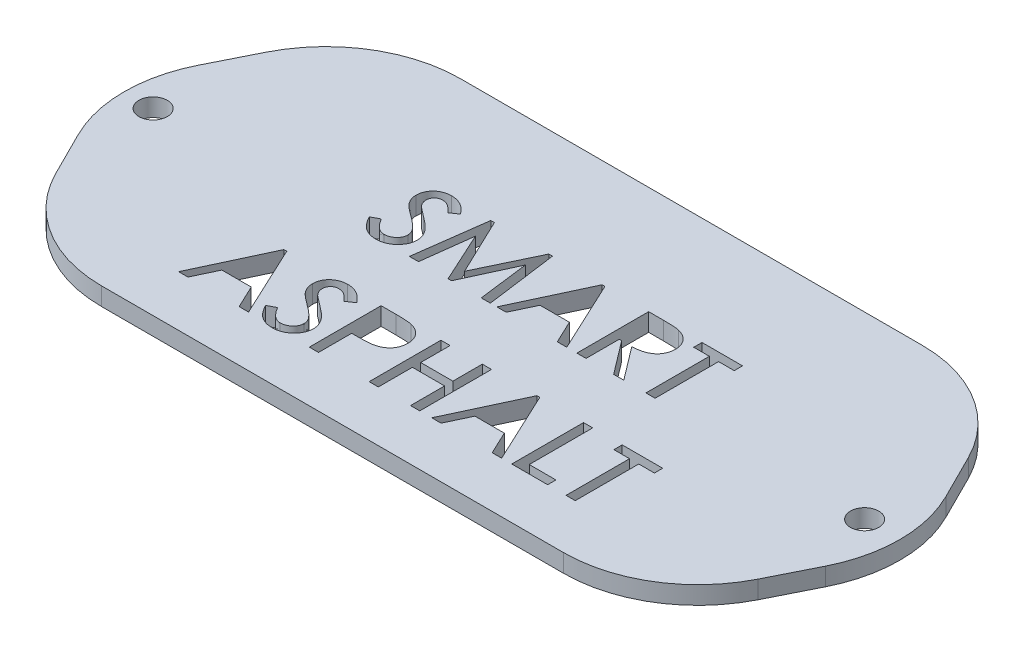
from build123d import *

# Parameters (mm, degrees)
SKETCH1_R           = 1.58
BOSS_EXTRUDE1_DEPTH = 2


with BuildPart() as part:
    # Sketch1 → Boss-Extrude1 (new body)
    with BuildSketch(Plane(origin=(0, 0, 0), x_dir=(1, 0, 0), z_dir=(0, 1, 0))):
        with BuildLine():
            Line((-22.537734094, 16.328045587), (28.921246244, 16.328045587))
            ThreePointArc((28.921246244, 16.328045587), (36.807212925, 14.087807712), (42.337654109, 8.03624952))
            Line((42.337654109, 8.03624952), (44.837654109, 3.03624952))
            ThreePointArc((44.837654109, 3.03624952), (46.421246244, -3.671954413), (44.837654109, -10.380158345))
            Line((44.837654109, -10.380158345), (42.337654109, -15.380158345))
            ThreePointArc((42.337654109, -15.380158345), (36.807212925, -21.431716538), (28.921246244, -23.671954413))
            Line((28.921246244, -23.671954413), (-22.537734094, -23.671954413))
            ThreePointArc((-22.537734094, -23.671954413), (-30.423700776, -21.431716538), (-35.954141959, -15.380158345))
            Line((-35.954141959, -15.380158345), (-38.454141959, -10.380158345))
            ThreePointArc((-38.454141959, -10.380158345), (-40.037734094, -3.671954413), (-38.454141959, 3.03624952))
            Line((-38.454141959, 3.03624952), (-35.954141959, 8.03624952))
            ThreePointArc((-35.954141959, 8.03624952), (-30.423700776, 14.087807712), (-22.537734094, 16.328045587))
        make_face()
        with Locations((-36.808243925, -3.671954413)):
            Circle(SKETCH1_R, mode=Mode.SUBTRACT)
        with Locations((42.491756075, -3.671954413)):
            Circle(SKETCH1_R, mode=Mode.SUBTRACT)
        with BuildLine():
            Line((-14.295423412, -2.085415951), (-13.423628541, -1.620672362))
            add(Edge.make_bspline(
                [(-13.423628541, -1.620672362), (-13.305977541, -1.823822274), (-13.11965558, -2.104826787), (-12.840981878, -2.429013334), (-12.641975401, -2.620035509), (-12.439309358, -2.767503703), (-12.174124296, -2.907234523), (-11.959744017, -2.954550086), (-11.819461874, -2.954005695)],
                knots=[0, 0, 0, 0, 0.32370907, 0.463075941, 0.588607122, 0.703049784, 0.807443722, 1, 1, 1, 1], degree=3))
            add(Edge.make_bspline(
                [(-11.819461874, -2.954005695), (-11.692092155, -2.95470975), (-11.502519693, -2.931184165), (-11.259792303, -2.85822019), (-11.087772674, -2.78133138), (-10.928852745, -2.686985532), (-10.788558793, -2.574802613), (-10.66953084, -2.447786333), (-10.57139736, -2.307668193), (-10.494571355, -2.158069642), (-10.41876587, -1.95177248), (-10.398814457, -1.78786225), (-10.397987515, -1.679967233)],
                knots=[0, 0, 0, 0, 0.179725759, 0.268080593, 0.357295441, 0.44532722, 0.528557861, 0.610268431, 0.690476304, 0.769478029, 0.847320812, 1, 1, 1, 1], degree=3))
            add(Edge.make_bspline(
                [(-10.397987515, -1.679967233), (-10.398026758, -1.554155823), (-10.444622826, -1.28975984), (-10.578321181, -1.057296377), (-10.6576029, -0.94439031)],
                knots=[0, 0, 0, 0, 0.475821556, 1, 1, 1, 1], degree=3))
            add(Edge.make_bspline(
                [(-10.6576029, -0.94439031), (-10.72881015, -0.851847822), (-10.847307389, -0.710190697), (-11.029700348, -0.526800598), (-11.193389654, -0.377355576), (-11.374829744, -0.219291995), (-11.654691855, 0.005896703), (-11.878604026, 0.172823824), (-12.034205464, 0.28637892)],
                knots=[0, 0, 0, 0, 0.189087639, 0.298560917, 0.418529035, 0.547896606, 0.688105638, 1, 1, 1, 1], degree=3))
            add(Edge.make_bspline(
                [(-12.034205464, 0.28637892), (-12.191879719, 0.399998124), (-12.414906191, 0.56550221), (-12.693382792, 0.782241412), (-12.867572439, 0.923745166), (-13.017234179, 1.053653978), (-13.171577156, 1.198226404), (-13.273773111, 1.302249279), (-13.327474694, 1.372917382)],
                knots=[0, 0, 0, 0, 0.344370415, 0.492060575, 0.625259646, 0.741997385, 0.843119601, 1, 1, 1, 1], degree=3))
            add(Edge.make_bspline(
                [(-13.327474694, 1.372917382), (-13.402102599, 1.46411598), (-13.500199247, 1.609591229), (-13.606124497, 1.814459744), (-13.670904852, 1.969206071), (-13.720955313, 2.12686807), (-13.76752052, 2.342319835), (-13.784730726, 2.507291479), (-13.7826029, 2.61810969)],
                knots=[0, 0, 0, 0, 0.261315157, 0.388035482, 0.511326802, 0.633179155, 0.754563498, 1, 1, 1, 1], degree=3))
            add(Edge.make_bspline(
                [(-13.7826029, 2.61810969), (-13.783205657, 2.789736668), (-13.75180998, 3.045415532), (-13.639654848, 3.366516604), (-13.526488342, 3.592433524), (-13.381777054, 3.801080634), (-13.209699504, 3.988334498), (-13.009268975, 4.150188935), (-12.785846887, 4.286604505), (-12.54502764, 4.397101902), (-12.204802693, 4.503406179), (-11.937354408, 4.532406833), (-11.758564438, 4.533173792)],
                knots=[0, 0, 0, 0, 0.165741364, 0.245990119, 0.327410354, 0.408957903, 0.490350364, 0.572108035, 0.656848456, 0.742472606, 0.827297737, 1, 1, 1, 1], degree=3))
            add(Edge.make_bspline(
                [(-11.758564438, 4.533173792), (-11.555658117, 4.530215554), (-11.250841757, 4.503701651), (-10.865660915, 4.383936181), (-10.634691398, 4.285936865), (-10.455261249, 4.185647236), (-10.319555213, 4.095081465), (-10.180466064, 3.992580807), (-10.042384872, 3.873052584), (-9.899990642, 3.742227388), (-9.708670566, 3.538082005), (-9.565317447, 3.377328115), (-9.474910592, 3.260737895)],
                knots=[0, 0, 0, 0, 0.224554627, 0.334220458, 0.444071551, 0.500820262, 0.560831712, 0.624033752, 0.691370994, 0.762285901, 0.837344076, 1, 1, 1, 1], degree=3))
            Line((-9.474910592, 3.260737895), (-10.311449053, 2.687019946))
            add(Edge.make_bspline(
                [(-10.311449053, 2.687019946), (-10.395268369, 2.776742918), (-10.516807362, 2.90574481), (-10.679347695, 3.064428123), (-10.78987395, 3.164936953), (-10.891628852, 3.253677156), (-10.987468947, 3.327659482), (-11.074397321, 3.391241874), (-11.183067067, 3.454266914), (-11.316278178, 3.516636931), (-11.536156228, 3.592164012), (-11.711537375, 3.607533697), (-11.827474694, 3.610096869)],
                knots=[0, 0, 0, 0, 0.200827508, 0.289794372, 0.371423664, 0.44514775, 0.510508429, 0.569413627, 0.62110701, 0.715687751, 0.809620671, 1, 1, 1, 1], degree=3))
            add(Edge.make_bspline(
                [(-11.827474694, 3.610096869), (-11.949476389, 3.610568548), (-12.131009374, 3.58030079), (-12.349199616, 3.475340574), (-12.491525157, 3.366296022), (-12.609707565, 3.231164291), (-12.728901524, 3.014496864), (-12.755686229, 2.825543476), (-12.756961874, 2.699840459)],
                knots=[0, 0, 0, 0, 0.251154334, 0.372198033, 0.495421983, 0.617857606, 0.739464963, 1, 1, 1, 1], degree=3))
            add(Edge.make_bspline(
                [(-12.756961874, 2.699840459), (-12.756045877, 2.614585853), (-12.746080283, 2.48617305), (-12.699074124, 2.322616278), (-12.654719469, 2.20197035), (-12.592546121, 2.083725284), (-12.483289733, 1.923104853), (-12.383439385, 1.810429321), (-12.309846489, 1.738301997)],
                knots=[0, 0, 0, 0, 0.234924047, 0.350690114, 0.466855841, 0.587687679, 0.71677411, 1, 1, 1, 1], degree=3))
            add(Edge.make_bspline(
                [(-12.309846489, 1.738301997), (-12.267367662, 1.695932769), (-12.187611069, 1.632748393), (-12.069646305, 1.537763894), (-11.953377618, 1.444241182), (-11.814394342, 1.341205132), (-11.593190792, 1.172290731), (-11.413905236, 1.04345051), (-11.289013156, 0.951443023)],
                knots=[0, 0, 0, 0, 0.139313951, 0.236560615, 0.352441789, 0.486424821, 0.63905089, 1, 1, 1, 1], degree=3))
            add(Edge.make_bspline(
                [(-11.289013156, 0.951443023), (-11.115577012, 0.825647118), (-10.864991132, 0.640860314), (-10.558318112, 0.382815208), (-10.354949126, 0.206424152), (-10.177000453, 0.03289888), (-10.021128504, -0.134181543), (-9.885389703, -0.293188842), (-9.740380011, -0.495918868), (-9.595638801, -0.745848277), (-9.425357596, -1.140313609), (-9.37416008, -1.452781883), (-9.372346489, -1.655928772)],
                knots=[0, 0, 0, 0, 0.191283692, 0.277593646, 0.357646669, 0.431478927, 0.499277499, 0.561538325, 0.61789992, 0.721500519, 0.818718062, 1, 1, 1, 1], degree=3))
            add(Edge.make_bspline(
                [(-9.372346489, -1.655928772), (-9.373277882, -1.797275354), (-9.393096316, -2.008792566), (-9.466360521, -2.280929737), (-9.54461972, -2.477473272), (-9.642345475, -2.669142814), (-9.763487741, -2.854259488), (-9.907685178, -3.03211082), (-10.068845015, -3.203771367), (-10.247047712, -3.361533779), (-10.438149787, -3.50038674), (-10.641567624, -3.616379237), (-10.855735009, -3.710503694), (-11.079390209, -3.787140303), (-11.397899835, -3.858488869), (-11.645839316, -3.875121383), (-11.813051617, -3.877082618)],
                knots=[0, 0, 0, 0, 0.115856589, 0.172975168, 0.230354731, 0.28888124, 0.348970969, 0.411239881, 0.476256751, 0.541680398, 0.605940103, 0.66945473, 0.733135015, 0.797354465, 0.86286589, 1, 1, 1, 1], degree=3))
            add(Edge.make_bspline(
                [(-11.813051617, -3.877082618), (-11.934993487, -3.875526739), (-12.117424737, -3.867322771), (-12.354850318, -3.822705065), (-12.527350822, -3.779977477), (-12.696058438, -3.725533889), (-12.85879362, -3.655900067), (-13.018267712, -3.575913648), (-13.173565547, -3.482258497), (-13.324885115, -3.372595452), (-13.473086909, -3.245298516), (-13.617307677, -3.098128728), (-13.760029451, -2.933002943), (-13.899326982, -2.74804421), (-14.085684676, -2.468267936), (-14.213196069, -2.24251418), (-14.295423412, -2.085415951)],
                knots=[0, 0, 0, 0, 0.11287497, 0.168077828, 0.22304391, 0.277068304, 0.331723036, 0.386484716, 0.441863941, 0.49914738, 0.55902149, 0.622215623, 0.689427227, 0.760626502, 0.836081358, 1, 1, 1, 1], degree=3))
        make_face(mode=Mode.SUBTRACT)
        Polygon((-8.244141361, -3.671954413), (-7.175231105, 4.328045587), (-6.771384951, 4.328045587), (-3.737731105, -2.030928772), (-0.704077258, 4.328045587), (-0.293820848, 4.328045587), (0.781499665, -3.671954413), (-0.236128541, -3.671954413), (-0.947667002, 1.969071228), (-3.543820848, -3.671954413), (-3.931641361, -3.671954413), (-6.519782387, 1.969071228), (-7.22811572, -3.671954413), align=None, mode=Mode.SUBTRACT)
        Polygon((5.550730434, 4.328045587), (9.294320177, -3.671954413), (8.241435562, -3.671954413), (7.026691972, -1.107851849), (3.754256075, -1.107851849), (2.539512485, -3.671954413), (1.499448383, -3.671954413), (5.230217613, 4.328045587), align=None, mode=Mode.SUBTRACT)
        with BuildLine():
            Line((10.422525306, 4.328045587), (12.060345818, 4.328045587))
            add(Edge.make_bspline(
                [(12.060345818, 4.328045587), (12.261765475, 4.328357237), (12.550780686, 4.32497616), (12.91840146, 4.31540816), (13.154417484, 4.301316317), (13.364643227, 4.288727562), (13.592113887, 4.263711118), (13.749645748, 4.243685522), (13.843999665, 4.220673792)],
                knots=[0, 0, 0, 0, 0.337633154, 0.484565566, 0.616400812, 0.733989578, 0.837532753, 1, 1, 1, 1], degree=3))
            add(Edge.make_bspline(
                [(13.843999665, 4.220673792), (13.971232618, 4.190946021), (14.156868583, 4.136216142), (14.390322718, 4.035835972), (14.552362973, 3.951065356), (14.704341117, 3.854994965), (14.843329727, 3.744791547), (14.974800694, 3.626067655), (15.093682275, 3.495102946), (15.201846018, 3.355837168), (15.29433056, 3.208295222), (15.373676863, 3.05445838), (15.439923576, 2.894555856), (15.489371111, 2.726802568), (15.536533074, 2.49159326), (15.552619601, 2.309991523), (15.550730434, 2.187019946)],
                knots=[0, 0, 0, 0, 0.135918359, 0.200616188, 0.263976667, 0.325923651, 0.387262425, 0.448207545, 0.509937464, 0.570935724, 0.631349428, 0.690727613, 0.750764729, 0.811048046, 0.872273526, 1, 1, 1, 1], degree=3))
            add(Edge.make_bspline(
                [(15.550730434, 2.187019946), (15.551382579, 1.986260995), (15.514922186, 1.686676699), (15.378825478, 1.313824461), (15.264478957, 1.097858164), (15.153092031, 0.937294968), (15.059855098, 0.8231476), (14.957346321, 0.716208944), (14.846298312, 0.615365884), (14.723787112, 0.52507486), (14.593550479, 0.439464277), (14.45405217, 0.360766194), (14.25297202, 0.266258189), (13.981005433, 0.167839406), (13.497785149, 0.051273439), (13.114219895, 0.023202578), (12.852012485, 0.020353279)],
                knots=[0, 0, 0, 0, 0.154645889, 0.2294332, 0.304482266, 0.342006236, 0.379701015, 0.417797289, 0.455937912, 0.494998246, 0.534798161, 0.575852582, 0.618154278, 0.705693043, 0.797937177, 1, 1, 1, 1], degree=3))
            Line((12.852012485, 0.020353279), (15.653294536, -3.671954413))
            Line((15.653294536, -3.671954413), (14.523486844, -3.671954413))
            Line((14.523486844, -3.671954413), (11.722204793, 0.020353279))
            Line((11.722204793, 0.020353279), (11.448166331, 0.020353279))
            Line((11.448166331, 0.020353279), (11.448166331, -3.671954413))
            Line((11.448166331, -3.671954413), (10.422525306, -3.671954413))
            Line((10.422525306, -3.671954413), (10.422525306, 4.328045587))
        make_face(mode=Mode.SUBTRACT)
        Polygon((16.371243254, 3.404968664), (16.371243254, 4.328045587), (20.884063767, 4.328045587), (20.884063767, 3.404968664), (19.140474024, 3.404968664), (19.140474024, -3.671954413), (18.114832998, -3.671954413), (18.114832998, 3.404968664), align=None, mode=Mode.SUBTRACT)
        Polygon((-15.577474694, -10.005287746), (-11.833884951, -18.005287746), (-12.886769566, -18.005287746), (-14.101513156, -15.441185182), (-17.373949053, -15.441185182), (-18.588692643, -18.005287746), (-19.628756746, -18.005287746), (-15.897987515, -10.005287746), align=None, mode=Mode.SUBTRACT)
        with BuildLine():
            Line((-11.526192643, -16.418749285), (-10.654397771, -15.954005695))
            add(Edge.make_bspline(
                [(-10.654397771, -15.954005695), (-10.536746772, -16.157155607), (-10.350424811, -16.43816012), (-10.071751108, -16.762346667), (-9.872744631, -16.953368843), (-9.670078589, -17.100837037), (-9.404893527, -17.240567856), (-9.190513248, -17.287883419), (-9.050231105, -17.287339028)],
                knots=[0, 0, 0, 0, 0.32370907, 0.463075941, 0.588607122, 0.703049784, 0.807443722, 1, 1, 1, 1], degree=3))
            add(Edge.make_bspline(
                [(-9.050231105, -17.287339028), (-8.922861385, -17.288043084), (-8.733288923, -17.264517498), (-8.490561534, -17.191553523), (-8.318541905, -17.114664713), (-8.159621976, -17.020318865), (-8.019328024, -16.908135946), (-7.900300071, -16.781119667), (-7.802166591, -16.641001527), (-7.725340586, -16.491402976), (-7.6495351, -16.285105813), (-7.629583687, -16.121195584), (-7.628756746, -16.013300567)],
                knots=[0, 0, 0, 0, 0.179725759, 0.268080593, 0.357295441, 0.44532722, 0.528557861, 0.610268431, 0.690476304, 0.769478029, 0.847320812, 1, 1, 1, 1], degree=3))
            add(Edge.make_bspline(
                [(-7.628756746, -16.013300567), (-7.628795989, -15.887489157), (-7.675392057, -15.623093173), (-7.809090412, -15.39062971), (-7.88837213, -15.277723644)],
                knots=[0, 0, 0, 0, 0.475821556, 1, 1, 1, 1], degree=3))
            add(Edge.make_bspline(
                [(-7.88837213, -15.277723644), (-7.95957938, -15.185181156), (-8.07807662, -15.043524031), (-8.260469579, -14.860133931), (-8.424158885, -14.710688909), (-8.605598974, -14.552625328), (-8.885461085, -14.32743663), (-9.109373257, -14.16050951), (-9.264974694, -14.046954413)],
                knots=[0, 0, 0, 0, 0.189087639, 0.298560917, 0.418529035, 0.547896606, 0.688105638, 1, 1, 1, 1], degree=3))
            add(Edge.make_bspline(
                [(-9.264974694, -14.046954413), (-9.42264895, -13.93333521), (-9.645675422, -13.767831123), (-9.924152022, -13.551091922), (-10.09834167, -13.409588168), (-10.24800341, -13.279679355), (-10.402346387, -13.13510693), (-10.504542342, -13.031084055), (-10.558243925, -12.960415951)],
                knots=[0, 0, 0, 0, 0.344370415, 0.492060575, 0.625259646, 0.741997385, 0.843119601, 1, 1, 1, 1], degree=3))
            add(Edge.make_bspline(
                [(-10.558243925, -12.960415951), (-10.63287183, -12.869217353), (-10.730968478, -12.723742104), (-10.836893728, -12.518873589), (-10.901674082, -12.364127263), (-10.951724543, -12.206465264), (-10.99828975, -11.991013498), (-11.015499957, -11.826041855), (-11.01337213, -11.715223644)],
                knots=[0, 0, 0, 0, 0.261315157, 0.388035482, 0.511326802, 0.633179155, 0.754563498, 1, 1, 1, 1], degree=3))
            add(Edge.make_bspline(
                [(-11.01337213, -11.715223644), (-11.013974888, -11.543596665), (-10.982579211, -11.287917802), (-10.870424078, -10.96681673), (-10.757257573, -10.740899809), (-10.612546285, -10.532252699), (-10.440468735, -10.344998835), (-10.240038206, -10.183144398), (-10.016616117, -10.046728828), (-9.775796871, -9.936231432), (-9.435571924, -9.829927155), (-9.168123639, -9.8009265), (-8.989333669, -9.800159541)],
                knots=[0, 0, 0, 0, 0.165741364, 0.245990119, 0.327410354, 0.408957903, 0.490350364, 0.572108035, 0.656848456, 0.742472606, 0.827297737, 1, 1, 1, 1], degree=3))
            add(Edge.make_bspline(
                [(-8.989333669, -9.800159541), (-8.786427348, -9.803117779), (-8.481610988, -9.829631682), (-8.096430146, -9.949397152), (-7.865460629, -10.047396468), (-7.68603048, -10.147686097), (-7.550324443, -10.238251868), (-7.411235294, -10.340752526), (-7.273154103, -10.46028075), (-7.130759873, -10.591105945), (-6.939439797, -10.795251328), (-6.796086678, -10.956005218), (-6.705679823, -11.072595439)],
                knots=[0, 0, 0, 0, 0.224554627, 0.334220458, 0.444071551, 0.500820262, 0.560831712, 0.624033752, 0.691370994, 0.762285901, 0.837344076, 1, 1, 1, 1], degree=3))
            Line((-6.705679823, -11.072595439), (-7.542218284, -11.646313387))
            add(Edge.make_bspline(
                [(-7.542218284, -11.646313387), (-7.6260376, -11.556590416), (-7.747576593, -11.427588523), (-7.910116926, -11.26890521), (-8.020643181, -11.168396381), (-8.122398082, -11.079656177), (-8.218238178, -11.005673852), (-8.305166551, -10.942091459), (-8.413836297, -10.879066419), (-8.547047409, -10.816696402), (-8.766925459, -10.741169321), (-8.942306605, -10.725799636), (-9.058243925, -10.723236464)],
                knots=[0, 0, 0, 0, 0.200827508, 0.289794372, 0.371423664, 0.44514775, 0.510508429, 0.569413627, 0.62110701, 0.715687751, 0.809620671, 1, 1, 1, 1], degree=3))
            add(Edge.make_bspline(
                [(-9.058243925, -10.723236464), (-9.18024562, -10.722764785), (-9.361778605, -10.753032543), (-9.579968847, -10.85799276), (-9.722294388, -10.967037311), (-9.840476796, -11.102169042), (-9.959670755, -11.318836469), (-9.98645546, -11.507789857), (-9.987731105, -11.633492874)],
                knots=[0, 0, 0, 0, 0.251154334, 0.372198033, 0.495421983, 0.617857606, 0.739464963, 1, 1, 1, 1], degree=3))
            add(Edge.make_bspline(
                [(-9.987731105, -11.633492874), (-9.986815108, -11.71874748), (-9.976849514, -11.847160283), (-9.929843354, -12.010717055), (-9.8854887, -12.131362983), (-9.823315352, -12.249608049), (-9.714058964, -12.41022848), (-9.614208616, -12.522904012), (-9.54061572, -12.595031336)],
                knots=[0, 0, 0, 0, 0.234924047, 0.350690114, 0.466855841, 0.587687679, 0.71677411, 1, 1, 1, 1], degree=3))
            add(Edge.make_bspline(
                [(-9.54061572, -12.595031336), (-9.498136893, -12.637400564), (-9.4183803, -12.70058494), (-9.300415535, -12.79556944), (-9.184146849, -12.889092151), (-9.045163573, -12.992128201), (-8.823960022, -13.161042602), (-8.644674467, -13.289882823), (-8.519782387, -13.38189031)],
                knots=[0, 0, 0, 0, 0.139313951, 0.236560615, 0.352441789, 0.486424821, 0.63905089, 1, 1, 1, 1], degree=3))
            add(Edge.make_bspline(
                [(-8.519782387, -13.38189031), (-8.346346243, -13.507686215), (-8.095760363, -13.692473019), (-7.789087343, -13.950518125), (-7.585718357, -14.126909181), (-7.407769684, -14.300434454), (-7.251897734, -14.467514876), (-7.116158933, -14.626522175), (-6.971149242, -14.829252201), (-6.826408032, -15.07918161), (-6.656126826, -15.473646943), (-6.60492931, -15.786115216), (-6.60311572, -15.989262105)],
                knots=[0, 0, 0, 0, 0.191283692, 0.277593646, 0.357646669, 0.431478927, 0.499277499, 0.561538325, 0.61789992, 0.721500519, 0.818718062, 1, 1, 1, 1], degree=3))
            add(Edge.make_bspline(
                [(-6.60311572, -15.989262105), (-6.604047113, -16.130608687), (-6.623865547, -16.342125899), (-6.697129752, -16.614263071), (-6.77538895, -16.810806605), (-6.873114706, -17.002476147), (-6.994256972, -17.187592821), (-7.138454409, -17.365444153), (-7.299614246, -17.537104701), (-7.477816943, -17.694867113), (-7.668919018, -17.833720073), (-7.872336855, -17.949712571), (-8.08650424, -18.043837028), (-8.31015944, -18.120473637), (-8.628669066, -18.191822202), (-8.876608546, -18.208454716), (-9.043820848, -18.210415951)],
                knots=[0, 0, 0, 0, 0.115856589, 0.172975168, 0.230354731, 0.28888124, 0.348970969, 0.411239881, 0.476256751, 0.541680398, 0.605940103, 0.66945473, 0.733135015, 0.797354465, 0.86286589, 1, 1, 1, 1], degree=3))
            add(Edge.make_bspline(
                [(-9.043820848, -18.210415951), (-9.165762717, -18.208860073), (-9.348193968, -18.200656105), (-9.585619549, -18.156038398), (-9.758120053, -18.11331081), (-9.926827668, -18.058867223), (-10.089562851, -17.989233401), (-10.249036943, -17.909246981), (-10.404334778, -17.81559183), (-10.555654345, -17.705928785), (-10.70385614, -17.57863185), (-10.848076907, -17.431462061), (-10.990798682, -17.266336277), (-11.130096213, -17.081377543), (-11.316453907, -16.80160127), (-11.443965299, -16.575847513), (-11.526192643, -16.418749285)],
                knots=[0, 0, 0, 0, 0.11287497, 0.168077828, 0.22304391, 0.277068304, 0.331723036, 0.386484716, 0.441863941, 0.49914738, 0.55902149, 0.622215623, 0.689427227, 0.760626502, 0.836081358, 1, 1, 1, 1], degree=3))
        make_face(mode=Mode.SUBTRACT)
        with BuildLine():
            Line((-5.064654182, -10.005287746), (-3.425231105, -10.005287746))
            add(Edge.make_bspline(
                [(-3.425231105, -10.005287746), (-3.217371576, -10.00338689), (-2.919306573, -10.010317778), (-2.540495482, -10.01978329), (-2.297340353, -10.032460552), (-2.082009999, -10.049969501), (-1.84935078, -10.075130901), (-1.689678498, -10.101237944), (-1.593500335, -10.12387749)],
                knots=[0, 0, 0, 0, 0.339081298, 0.486441487, 0.618233496, 0.73628572, 0.83888723, 1, 1, 1, 1], degree=3))
            add(Edge.make_bspline(
                [(-1.593500335, -10.12387749), (-1.46983081, -10.152304585), (-1.291368552, -10.210268003), (-1.0659909, -10.310695358), (-0.908845279, -10.394828753), (-0.762875358, -10.49208407), (-0.624907928, -10.597729149), (-0.499192907, -10.717132778), (-0.381421629, -10.844495802), (-0.278088821, -10.982729079), (-0.185501176, -11.127154784), (-0.108764228, -11.279870605), (-0.045683972, -11.440309136), (0.003569398, -11.607631311), (0.051842859, -11.844256222), (0.063997848, -12.027330741), (0.063550947, -12.15112108)],
                knots=[0, 0, 0, 0, 0.13385232, 0.197460199, 0.260283448, 0.321745706, 0.38242703, 0.443463615, 0.504531448, 0.565317476, 0.625387916, 0.685405402, 0.745404344, 0.807137595, 0.869286633, 1, 1, 1, 1], degree=3))
            add(Edge.make_bspline(
                [(0.063550947, -12.15112108), (0.063851347, -12.27542032), (0.051876337, -12.459600925), (0.003595, -12.696582943), (-0.044213546, -12.864700889), (-0.107118012, -13.024789935), (-0.182265796, -13.178198551), (-0.273109826, -13.323189443), (-0.376817766, -13.460768846), (-0.493933987, -13.5888223), (-0.622760623, -13.706864565), (-0.764991722, -13.812830992), (-0.919166365, -13.908635575), (-1.084755697, -13.995911568), (-1.327726537, -14.098205557), (-1.521594682, -14.153970707), (-1.654397771, -14.18637749)],
                knots=[0, 0, 0, 0, 0.128475639, 0.189840893, 0.249574007, 0.30880794, 0.36729943, 0.425796127, 0.485286573, 0.545052818, 0.604819063, 0.665523182, 0.727997529, 0.792176702, 0.858697628, 1, 1, 1, 1], degree=3))
            add(Edge.make_bspline(
                [(-1.654397771, -14.18637749), (-1.762070693, -14.212065736), (-1.941018982, -14.24039435), (-2.200649565, -14.26488747), (-2.440027405, -14.282363704), (-2.708752545, -14.296923817), (-3.127600392, -14.309227534), (-3.456709925, -14.314136994), (-3.686449053, -14.312980054)],
                knots=[0, 0, 0, 0, 0.16272606, 0.266179012, 0.383590383, 0.515803696, 0.662049157, 1, 1, 1, 1], degree=3))
            Line((-3.686449053, -14.312980054), (-4.039013156, -14.312980054))
            Line((-4.039013156, -14.312980054), (-4.039013156, -18.005287746))
            Line((-4.039013156, -18.005287746), (-5.064654182, -18.005287746))
            Line((-5.064654182, -18.005287746), (-5.064654182, -10.005287746))
        make_face(mode=Mode.SUBTRACT)
        Polygon((1.602012485, -10.005287746), (2.627653511, -10.005287746), (2.627653511, -13.287339028), (6.2173971, -13.287339028), (6.2173971, -10.005287746), (7.243038126, -10.005287746), (7.243038126, -18.005287746), (6.2173971, -18.005287746), (6.2173971, -14.210415951), (2.627653511, -14.210415951), (2.627653511, -18.005287746), (1.602012485, -18.005287746), align=None, mode=Mode.SUBTRACT)
        Polygon((12.627653511, -10.005287746), (16.371243254, -18.005287746), (15.318358639, -18.005287746), (14.103615049, -15.441185182), (10.831179152, -15.441185182), (9.616435562, -18.005287746), (8.576371459, -18.005287746), (12.30714069, -10.005287746), align=None, mode=Mode.SUBTRACT)
        Polygon((17.499448383, -10.005287746), (18.525089408, -10.005287746), (18.525089408, -17.082210823), (21.499448383, -17.082210823), (21.499448383, -18.005287746), (17.499448383, -18.005287746), align=None, mode=Mode.SUBTRACT)
        Polygon((21.80714069, -10.928364669), (21.80714069, -10.005287746), (26.319961203, -10.005287746), (26.319961203, -10.928364669), (24.576371459, -10.928364669), (24.576371459, -18.005287746), (23.550730434, -18.005287746), (23.550730434, -10.928364669), align=None, mode=Mode.SUBTRACT)
    extrude(amount=BOSS_EXTRUDE1_DEPTH)


solid = part.part
